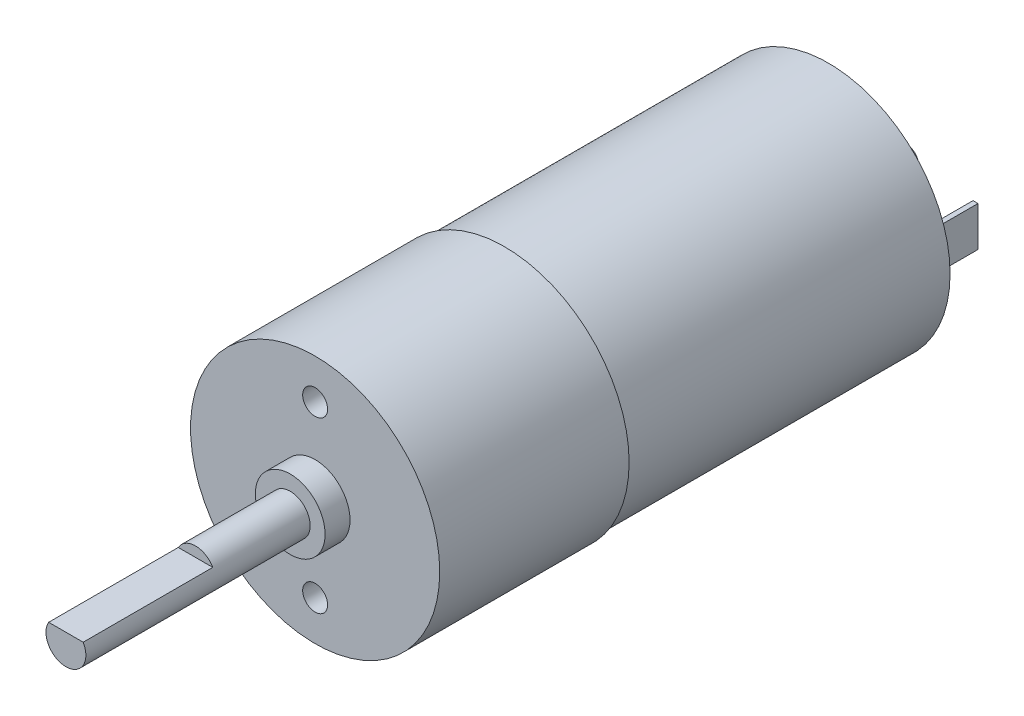
from build123d import *

# Parameters (mm, degrees)
SKETCH_1_R          = 12.5
EXTRUDE_1_DEPTH     = 19
SKETCH_2_R          = 3.5
EXTRUDE_2_DEPTH     = 2.5
SKETCH_3_R          = 2
EXTRUDE_3_DEPTH     = 22.5
SKETCH_4_W          = 6.562487183
SKETCH_4_H          = 1.182107807
CUT_EXTRUDE_1_DEPTH = 13
SKETCH_5_R          = 12.2
EXTRUDE_5_DEPTH     = 32.5
SKETCH_6_R          = 3.5
EXTRUDE_6_DEPTH     = 3
SKETCH_7_R          = 1
EXTRUDE_7_DEPTH     = 5
SKETCH_8_R          = 1.25
CUT_EXTRUDE_2_DEPTH = 5
SKETCH_9_W          = 0.5
SKETCH_9_H          = 4
EXTRUDE_8_DEPTH     = 5.5


with BuildPart() as part:
    # 스케치1 → 보스-돌출1 (new body)
    with BuildSketch(Plane.XY):
        Circle(SKETCH_1_R)
    extrude(amount=EXTRUDE_1_DEPTH)

    # 스케치2 → 보스-돌출2 (add)
    with BuildSketch(Plane.XY.offset(19)):
        Circle(SKETCH_2_R)
    extrude(amount=EXTRUDE_2_DEPTH)

    # 스케치3 → 보스-돌출3 (add)
    with BuildSketch(Plane.XY.offset(21.5)):
        Circle(SKETCH_3_R)
    extrude(amount=EXTRUDE_3_DEPTH)

    # 스케치4 → 컷-돌출1 (cut)
    with BuildSketch(Plane.XY.offset(44)):
        with Locations((0.048491285, 1.591053903)):
            Rectangle(SKETCH_4_W, SKETCH_4_H)
    extrude(amount=-CUT_EXTRUDE_1_DEPTH, mode=Mode.SUBTRACT)

    # 스케치5 → 보스-돌출5 (add)
    with BuildSketch(Plane(origin=(0, 0, 0), x_dir=(-1, 0, 0), z_dir=(0, 0, -1))):
        Circle(SKETCH_5_R)
    extrude(amount=EXTRUDE_5_DEPTH)

    # 스케치6 → 보스-돌출6 (add)
    with BuildSketch(Plane(origin=(0, 0, -32.5), x_dir=(-1, 0, 0), z_dir=(0, 0, -1))):
        Circle(SKETCH_6_R)
    extrude(amount=EXTRUDE_6_DEPTH)

    # 스케치7 → 보스-돌출7 (add)
    with BuildSketch(Plane(origin=(0, 0, -35.5), x_dir=(-1, 0, 0), z_dir=(0, 0, -1))):
        Circle(SKETCH_7_R)
    extrude(amount=EXTRUDE_7_DEPTH)

    # 스케치8 → 컷-돌출2 (cut)
    with BuildSketch(Plane.XY.offset(19)):
        with Locations((0, 8.5)):
            Circle(SKETCH_8_R)
        with Locations((0, -8.5)):
            Circle(SKETCH_8_R)
    extrude(amount=-CUT_EXTRUDE_2_DEPTH, mode=Mode.SUBTRACT)

    # 스케치9 → 보스-돌출8 (add)
    with BuildSketch(Plane(origin=(0, 0, -32.5), x_dir=(-1, 0, 0), z_dir=(0, 0, -1))):
        with Locations((-9.25, 0)):
            Rectangle(SKETCH_9_W, SKETCH_9_H)
        with Locations((9.25, 0)):
            Rectangle(SKETCH_9_W, SKETCH_9_H)
    extrude(amount=EXTRUDE_8_DEPTH)


solid = part.part
